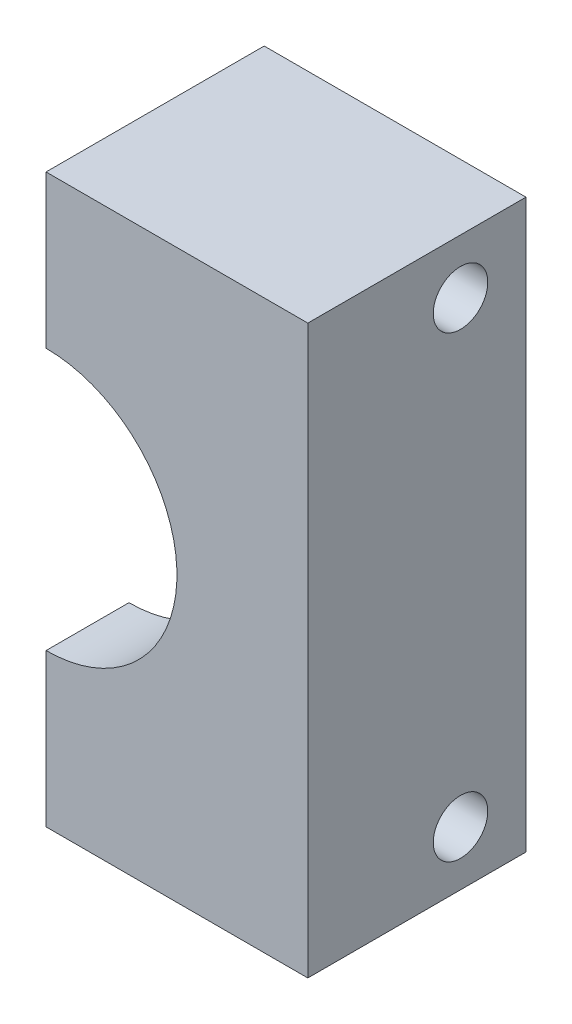
from build123d import *

# Parameters (mm, degrees)
BOSS_EXTRU_1_DEPTH      = 10
BOSS_EXTRU_2_DEPTH      = 3.8
ESQUISSE3_R             = 1.25
ENL_V_MAT_EXTRU_1_DEPTH = 13


with BuildPart() as part:
    # Esquisse1 → Boss.-Extru.1 (new body)
    with BuildSketch(Plane.XY):
        with BuildLine():
            Line((-12, 0), (0, 0))
            Line((0, 0), (0, 26))
            Line((0, 26), (-12, 26))
            Line((-12, 26), (-12, 21))
            ThreePointArc((-12, 21), (-6.343145751, 18.656854249), (-4, 13))
            ThreePointArc((-4, 13), (-6.343145751, 7.343145751), (-12, 5))
            Line((-12, 5), (-12, 0))
        make_face()
    extrude(amount=BOSS_EXTRU_1_DEPTH)

    # Esquisse2 → Boss.-Extru.2 (add)
    with BuildSketch(Plane.XY.offset(10)):
        with BuildLine():
            ThreePointArc((-12, 5), (-4, 13), (-12, 21))
            Line((-12, 21), (-12, 19))
            ThreePointArc((-12, 19), (-7.757359313, 17.242640687), (-6, 13))
            ThreePointArc((-6, 13), (-7.757359313, 8.757359313), (-12, 7))
            Line((-12, 7), (-12, 5))
        make_face()
    extrude(amount=-BOSS_EXTRU_2_DEPTH)

    # Esquisse3 → Enlèv. mat.-Extru.1 (cut, through all)
    with BuildSketch(Plane.ZY.offset(12)):
        with Locations((3, 23.5)):
            Circle(ESQUISSE3_R)
        with Locations((3, 2.5)):
            Circle(ESQUISSE3_R)
    extrude(amount=-ENL_V_MAT_EXTRU_1_DEPTH, mode=Mode.SUBTRACT)


solid = part.part
